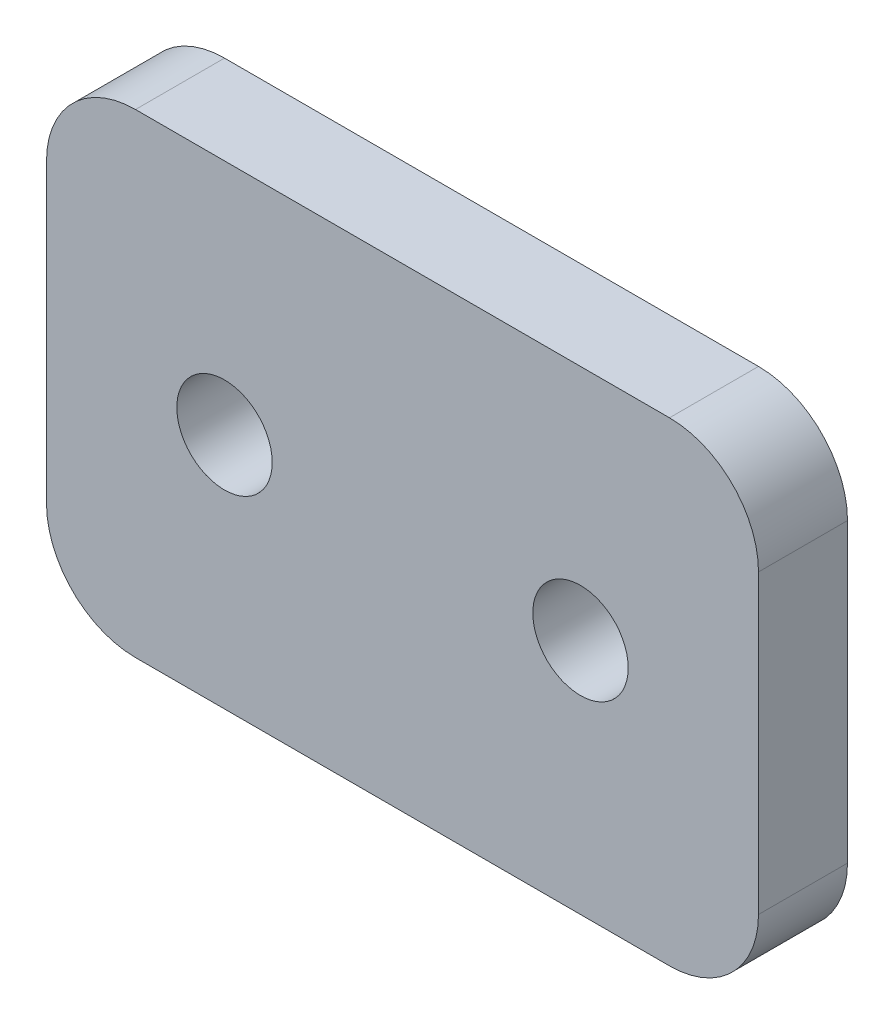
from build123d import *

# Parameters (mm, degrees)
SKETCH2_W           = 38.1
SKETCH2_H           = 25.4
SKETCH2_R           = 2.5527
BOSS_EXTRUDE1_DEPTH = 4.7625
FILLET1_R           = 4.7625


with BuildPart() as part:
    # Sketch2 → Boss-Extrude1 (new body)
    with BuildSketch(Plane.XY):
        with Locations((19.05, 12.7)):
            Rectangle(SKETCH2_W, SKETCH2_H)
        with Locations((9.525, 12.7)):
            Circle(SKETCH2_R, mode=Mode.SUBTRACT)
        with Locations((28.575, 12.7)):
            Circle(SKETCH2_R, mode=Mode.SUBTRACT)
    extrude(amount=BOSS_EXTRUDE1_DEPTH)

    # Fillet1
    fillet1_edges = [part.edges().sort_by_distance(p)[0] for p in [
        (0, 25.4, 2.38125),
        (38.1, 25.4, 2.38125),
        (38.1, 0, 2.38125),
        (0, 0, 2.38125),
    ]]
    fillet(fillet1_edges, radius=FILLET1_R)


solid = part.part
